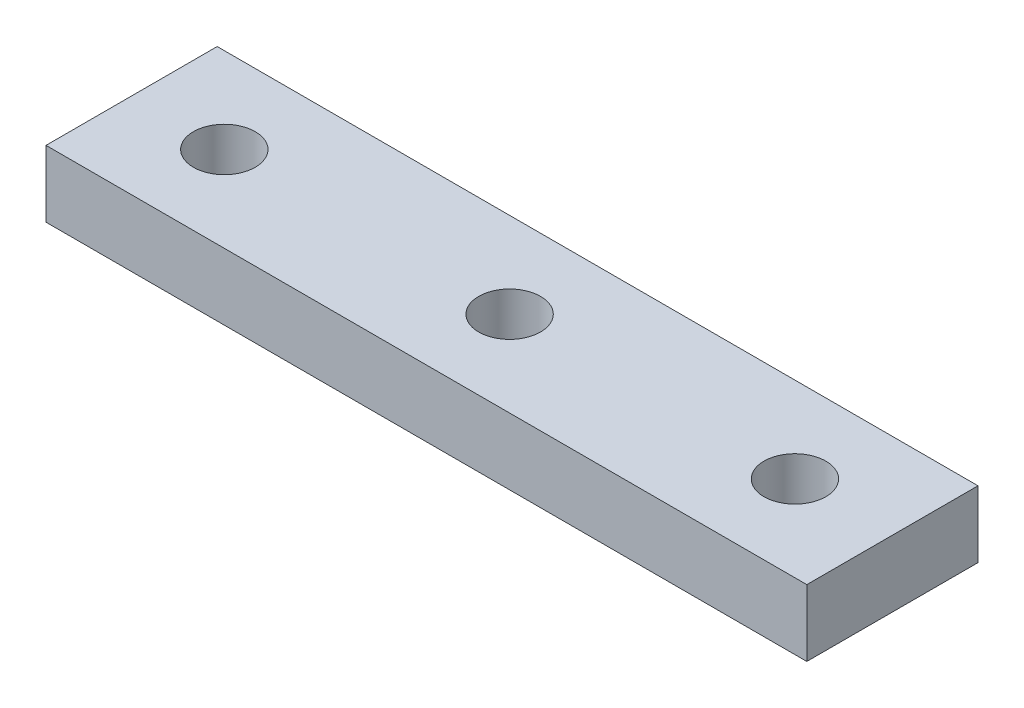
from build123d import *

# Parameters (mm, degrees)
SKETCH_1_W          = 80
SKETCH_1_H          = 18
EXTRUDE_1_DEPTH     = 7
SKETCH_2_R          = 3.25
CUT_EXTRUDE_1_DEPTH = 5
SKETCH_3_R          = 1.75
CUT_EXTRUDE_3_DEPTH = 8


with BuildPart() as part:
    # 草图1 → 凸台-拉伸1 (new body)
    with BuildSketch(Plane(origin=(0, 0, 0), x_dir=(1, 0, 0), z_dir=(0, 1, 0))):
        with Locations((40, -9)):
            Rectangle(SKETCH_1_W, SKETCH_1_H)
    extrude(amount=EXTRUDE_1_DEPTH)

    # 草图2 → 切除-拉伸1 (cut)
    with BuildSketch(Plane(origin=(0, 7, 0), x_dir=(1, 0, 0), z_dir=(0, 1, 0))):
        with Locations((9.75, -9)):
            Circle(SKETCH_2_R)
        with Locations((39.75, -9)):
            Circle(SKETCH_2_R)
        with Locations((69.75, -9)):
            Circle(SKETCH_2_R)
    extrude(amount=-CUT_EXTRUDE_1_DEPTH, mode=Mode.SUBTRACT)

    # 草图3 → 切除-拉伸3 (cut, through all)
    with BuildSketch(Plane.XZ):
        with Locations((9.75, 9)):
            Circle(SKETCH_3_R)
        with Locations((39.75, 9)):
            Circle(SKETCH_3_R)
        with Locations((69.75, 9)):
            Circle(SKETCH_3_R)
    extrude(amount=-CUT_EXTRUDE_3_DEPTH, mode=Mode.SUBTRACT)


solid = part.part
